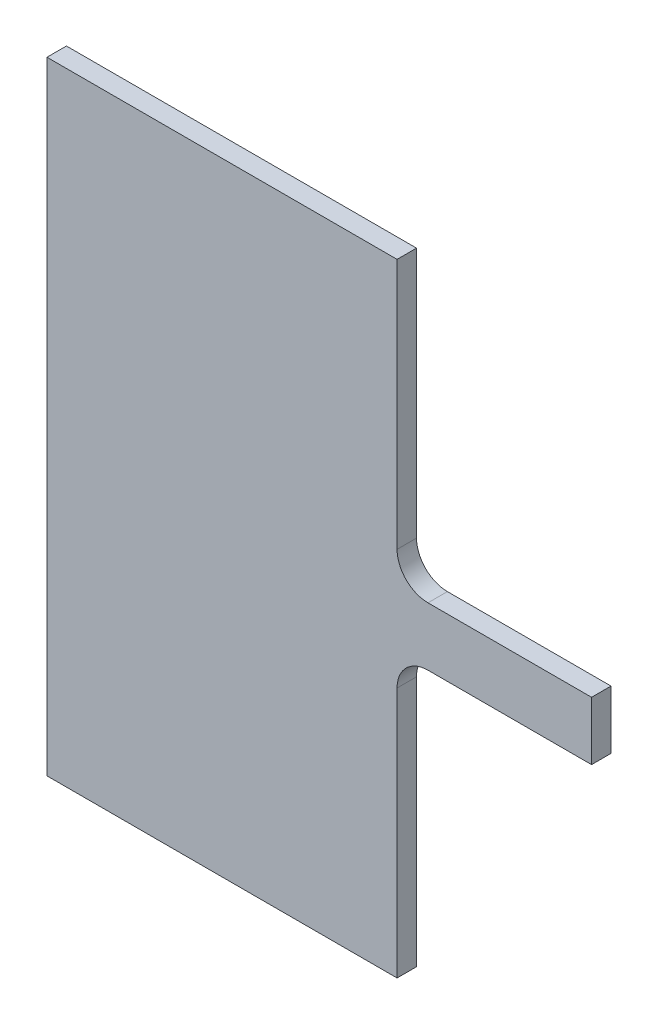
from build123d import *

# Parameters (mm, degrees)
BOSS_EXTRUDE1_DEPTH = 1


with BuildPart() as part:
    # Sketch1 → Boss-Extrude1 (new body)
    with BuildSketch(Plane.XY):
        with BuildLine():
            Line((29.736292646, -7), (11.736292646, -7))
            Line((11.736292646, -7), (11.736292646, 25))
            Line((11.736292646, 25), (29.736292646, 25))
            Line((29.736292646, 25), (29.736292646, 12.0875))
            ThreePointArc((29.736292646, 12.0875), (30.201260631, 10.964967985), (31.323792646, 10.5))
            Line((31.323792646, 10.5), (39.736292646, 10.5))
            Line((39.736292646, 10.5), (39.736292646, 7.5))
            Line((39.736292646, 7.5), (31.323792646, 7.5))
            ThreePointArc((31.323792646, 7.5), (30.201260631, 7.035032015), (29.736292646, 5.9125))
            Line((29.736292646, 5.9125), (29.736292646, -7))
        make_face()
    extrude(amount=BOSS_EXTRUDE1_DEPTH)


solid = part.part
